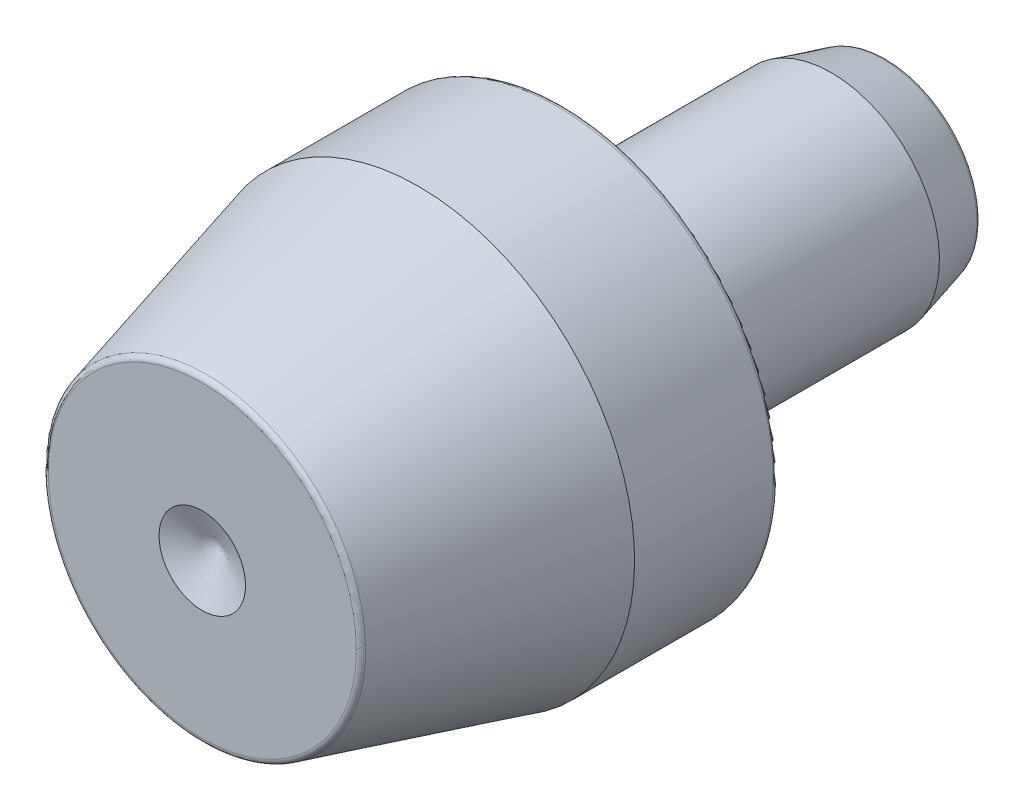
from build123d import *


with BuildPart() as part:
    # Sketch1 → Revolve1 (revolve)
    with BuildSketch(Plane(origin=(0, 0, 0), x_dir=(0, 0, -1), z_dir=(1, 0, 0))):
        with BuildLine():
            Line((-9.5, 1.2), (-9.5, 4.274328321))
            ThreePointArc((-9.5, 4.274328321), (-9.468228076, 4.367925391), (-9.386043428, 4.422839417))
            Line((-9.386043428, 4.422839417), (-3.5, 6))
            Line((-3.5, 6), (0.34625, 6))
            ThreePointArc((0.34625, 6), (0.454967668, 5.954967668), (0.5, 5.84625))
            Line((0.5, 5.84625), (0.5, 3.46125))
            ThreePointArc((0.5, 3.46125), (0.391282332, 3.416217668), (0.34625, 3.3075))
            Line((0.34625, 3.3075), (0.34625, 3))
            ThreePointArc((0.34625, 3), (0.391282332, 2.891282332), (0.5, 2.84625))
            Line((0.5, 2.84625), (1.26875, 2.84625))
            Line((1.26875, 2.84625), (1.4225, 3))
            Line((1.4225, 3), (7.9625, 3))
            Line((7.9625, 3), (9.386043428, 2.618562688))
            ThreePointArc((9.386043428, 2.618562688), (9.468228076, 2.563648662), (9.5, 2.470051592))
            Line((9.5, 2.470051592), (9.5, 0))
            Line((9.5, 0), (-9.002943725, 0))
            Line((-9.002943725, 0), (-9.5, 1.2))
        make_face()
    revolve(axis=Axis((0, 0, -9.5), (0, 0, 1)))


solid = part.part
